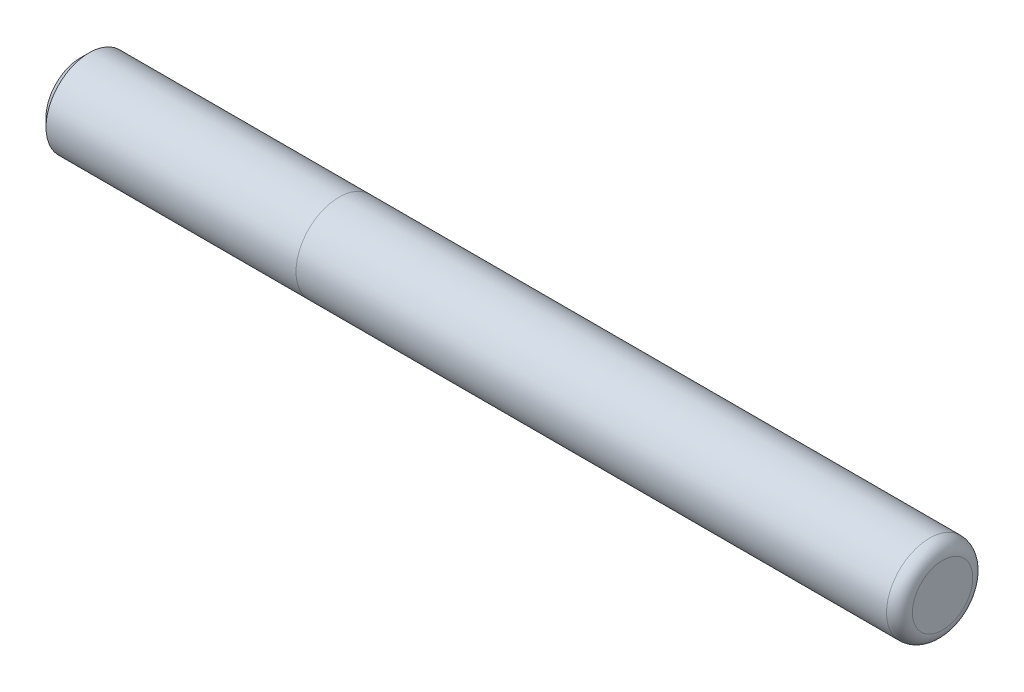
from build123d import *


with BuildPart() as part:
    # Esquisse1 → Révolution1 (revolve)
    with BuildSketch(Plane.XY):
        with BuildLine():
            Line((-100, 0), (0, 0))
            Line((0, 0), (0, 3.5))
            ThreePointArc((0, 3.5), (-0.439339828, 4.560660172), (-1.5, 5))
            Line((-1.5, 5), (-70, 5))
            Line((-70, 5), (-70, 4.999))
            Line((-70, 4.999), (-99, 4.999))
            Line((-99, 4.999), (-100, 3.999))
            Line((-100, 3.999), (-100, 0))
        make_face()
    revolve(axis=Axis((-100, 0, 0), (1, 0, 0)))


solid = part.part
